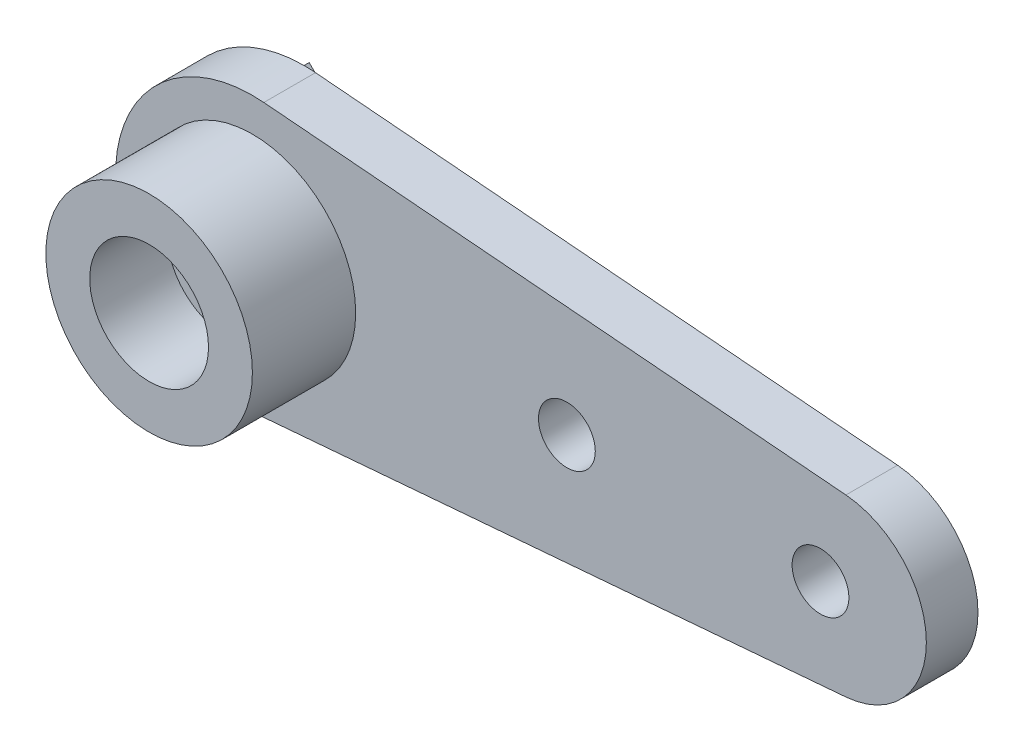
from build123d import *

# Parameters (mm, degrees)
SKETCH1_R           = 2.921
SKETCH1_R_2         = 1.397
BOSS_EXTRUDE1_DEPTH = 2.54
SKETCH2_R           = 5.08
SKETCH2_R_2         = 2.921
BOSS_EXTRUDE2_DEPTH = 5.08
SKETCH3_R           = 2.921
SKETCH3_R_2         = 1.8415
BOSS_EXTRUDE3_DEPTH = 1.27
BOSS_EXTRUDE4_DEPTH = 0.254


with BuildPart() as part:
    # Sketch1 → Boss-Extrude1 (new body)
    with BuildSketch(Plane.XY):
        with BuildLine():
            ThreePointArc((29.190418502, -4.302847972), (33.147, 0), (29.190418502, 4.302847972))
            Line((29.190418502, 4.302847972), (0.563387665, 6.707380662))
            ThreePointArc((0.563387665, 6.707380662), (-6.731, 0), (0.563387665, -6.707380662))
            Line((0.563387665, -6.707380662), (29.190418502, -4.302847972))
        make_face()
        Circle(SKETCH1_R, mode=Mode.SUBTRACT)
        with Locations((15.466782925, 0)):
            Circle(SKETCH1_R_2, mode=Mode.SUBTRACT)
        with Locations((27.940644271, 0)):
            Circle(SKETCH1_R_2, mode=Mode.SUBTRACT)
    extrude(amount=BOSS_EXTRUDE1_DEPTH)

    # Sketch2 → Boss-Extrude2 (add)
    with BuildSketch(Plane.XY.offset(2.54)):
        Circle(SKETCH2_R)
        Circle(SKETCH2_R_2, mode=Mode.SUBTRACT)
    extrude(amount=BOSS_EXTRUDE2_DEPTH)

    # Sketch3 → Boss-Extrude3 (add)
    with BuildSketch(Plane.XY.offset(2.54)):
        Circle(SKETCH3_R)
        Circle(SKETCH3_R_2, mode=Mode.SUBTRACT)
    extrude(amount=BOSS_EXTRUDE3_DEPTH)

    # Sketch4 → Boss-Extrude4 (add)
    with BuildSketch(Plane(origin=(0, 0, 0), x_dir=(-1, 0, 0), z_dir=(0, 0, -1))):
        Polygon((6.731, 0), (0, 6.731), (-1.116069724, 5.614930276), (5.614930276, -1.116069724), align=None)
    extrude(amount=BOSS_EXTRUDE4_DEPTH)


solid = part.part
